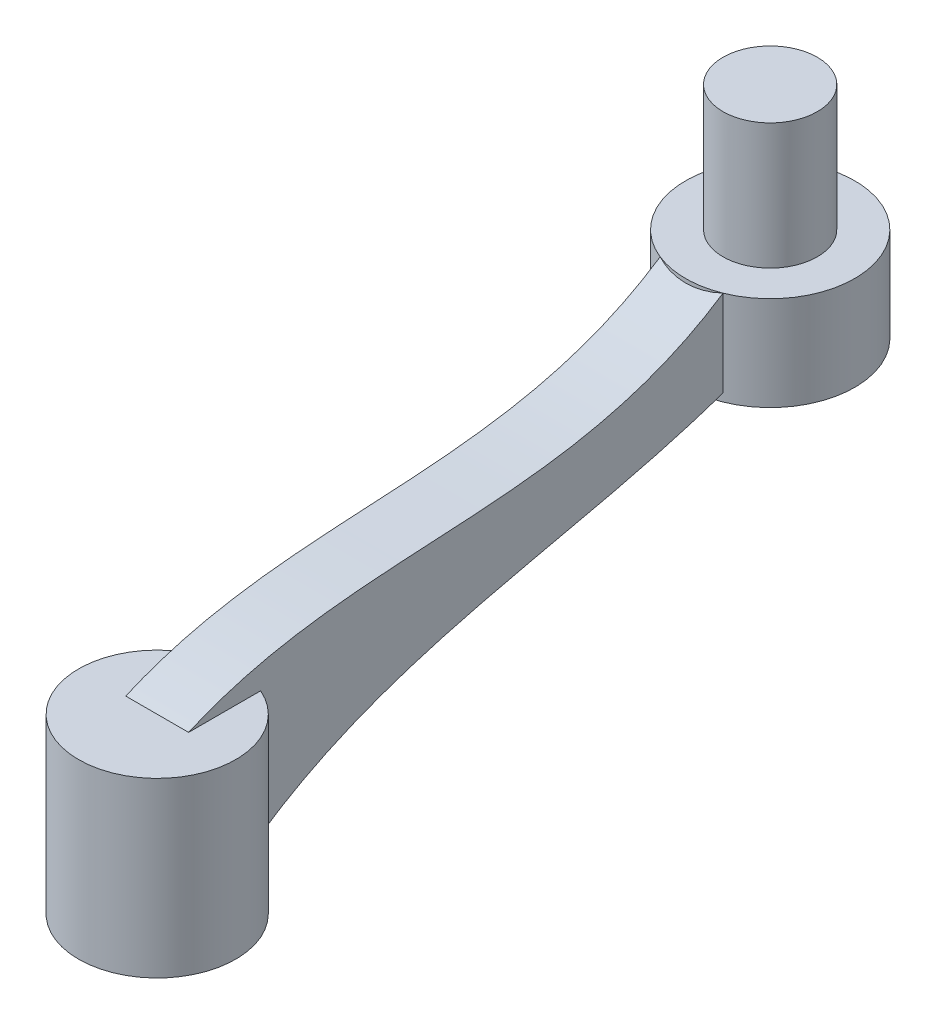
from build123d import *

# Parameters (mm, degrees)
SKETCH1_R           = 12.5
SKETCH1_R_2         = 7.5005
BOSS_EXTRUDE1_DEPTH = 25
BOSS_EXTRUDE2_START = 25
SKETCH1_3_R         = 12.5
SKETCH1_3_R_2       = 7.5005
BOSS_EXTRUDE2_DEPTH = 2.5
BOSS_EXTRUDE5_DEPTH = 5
SKETCH3_R           = 13.462912018
BOSS_EXTRUDE6_DEPTH = 15
SKETCH4_R           = 7.5
BOSS_EXTRUDE7_DEPTH = 20


with BuildPart() as part:
    # Sketch1 → Boss-Extrude1 (new body)
    with BuildSketch(Plane(origin=(0, 0, 0), x_dir=(1, 0, 0), z_dir=(0, 1, 0))):
        Circle(SKETCH1_R)
        Circle(SKETCH1_R_2, mode=Mode.SUBTRACT)
    extrude(amount=BOSS_EXTRUDE1_DEPTH)

    # Sketch1_3 → Boss-Extrude2 (add)
    with BuildSketch(Plane(origin=(0, 0, 0), x_dir=(1, 0, 0), z_dir=(0, 1, 0)).offset(BOSS_EXTRUDE2_START)):
        Circle(SKETCH1_3_R)
        Circle(SKETCH1_3_R_2, mode=Mode.SUBTRACT)
        Circle(SKETCH1_3_R_2)
    extrude(amount=BOSS_EXTRUDE2_DEPTH)

    # Sketch2 → Boss-Extrude5 (add, symmetric)
    with BuildSketch(Plane(origin=(0, 0, 0), x_dir=(0, 0, -1), z_dir=(1, 0, 0))):
        with BuildLine():
            Line((110, 45.5), (85, 45.5))
            add(Edge.make_bspline(
                [(0, 27.5), (27.318342435, 39.481167594), (59.380064257, 28.466617173), (85, 45.5)],
                knots=[0, 0, 0, 0, 1, 1, 1, 1], degree=3))
            Line((0, 27.5), (10.078558278, 27.5))
            Line((10.078558278, 27.5), (10.078558278, 6.752961332))
            add(Edge.make_bspline(
                [(10.078558278, 6.752961332), (40.207506706, 28.515228395), (81.426628227, 21.377572534), (110, 45.5)],
                knots=[0, 0, 0, 0, 1, 1, 1, 1], degree=3))
        make_face()
    extrude(amount=BOSS_EXTRUDE5_DEPTH, both=True)

    # Sketch3 → Boss-Extrude6 (add)
    with BuildSketch(Plane(origin=(0, 45.5, 0), x_dir=(1, 0, 0), z_dir=(0, 1, 0))):
        with Locations((0, 97.5)):
            Circle(SKETCH3_R)
    extrude(amount=-BOSS_EXTRUDE6_DEPTH)

    # Sketch4 → Boss-Extrude7 (add)
    with BuildSketch(Plane(origin=(0, 45.5, 0), x_dir=(1, 0, 0), z_dir=(0, 1, 0))):
        with Locations((0, 97.5)):
            Circle(SKETCH4_R)
    extrude(amount=BOSS_EXTRUDE7_DEPTH)


solid = part.part
